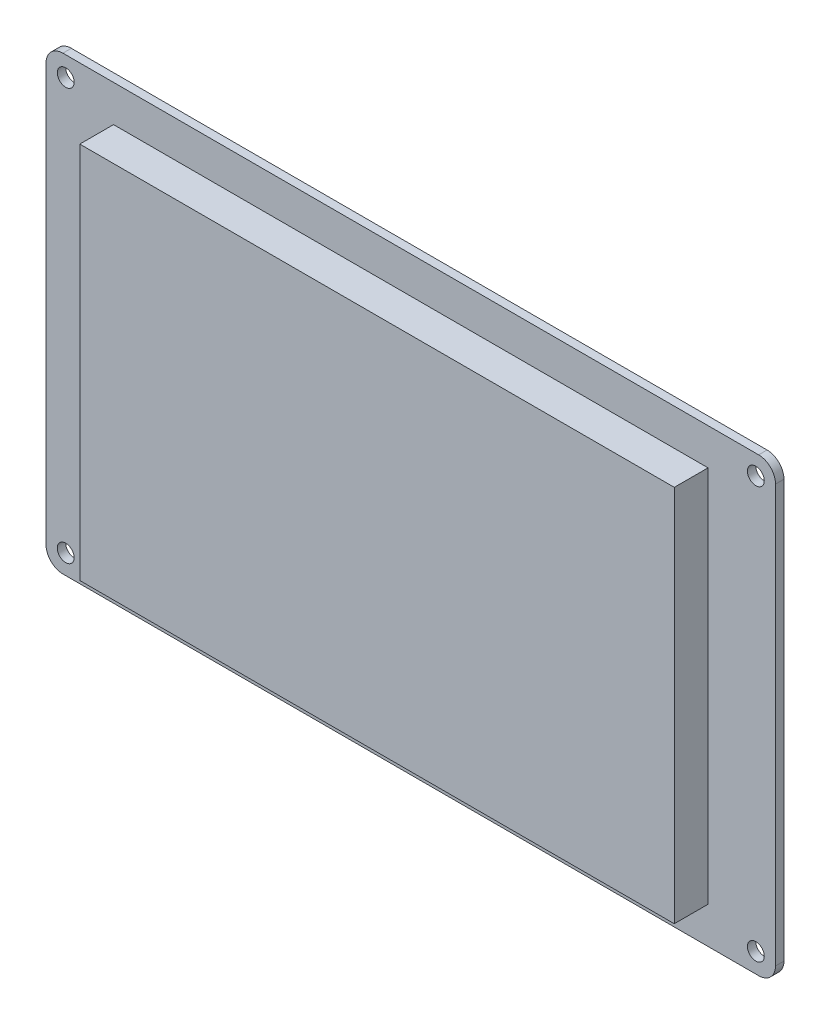
from build123d import *

# Parameters (mm, degrees)
SKETCH1_W           = 105.7
SKETCH1_H           = 67.2
BOSS_EXTRUDE1_DEPTH = 6
SKETCH2_W           = 129.7
SKETCH2_H           = 80.2
BOSS_EXTRUDE2_DEPTH = 1.5
SKETCH3_R           = 1.5
CUT_EXTRUDE1_DEPTH  = 1.5
FILLET1_R           = 3


with BuildPart() as part:
    # Sketch1 → Boss-Extrude1 (new body)
    with BuildSketch(Plane.XY):
        Rectangle(SKETCH1_W, SKETCH1_H)
    extrude(amount=BOSS_EXTRUDE1_DEPTH)

    # Sketch2 → Boss-Extrude2 (add)
    with BuildSketch(Plane(origin=(0, 0, 0), x_dir=(-1, 0, 0), z_dir=(0, 0, -1))):
        Rectangle(SKETCH2_W, SKETCH2_H)
    extrude(amount=BOSS_EXTRUDE2_DEPTH)

    # Sketch3 → Cut-Extrude1 (cut)
    with BuildSketch(Plane.XY):
        with Locations((61.35, 36.6)):
            Circle(SKETCH3_R)
        with Locations((61.35, -36.6)):
            Circle(SKETCH3_R)
        with Locations((-61.35, -36.6)):
            Circle(SKETCH3_R)
        with Locations((-61.35, 36.6)):
            Circle(SKETCH3_R)
    extrude(amount=-CUT_EXTRUDE1_DEPTH, mode=Mode.SUBTRACT)

    # Fillet1
    fillet1_edges = [part.edges().sort_by_distance(p)[0] for p in [
        (-64.85, -40.1, -0.75),
        (-64.85, 40.1, -0.75),
        (64.85, 40.1, -0.75),
        (64.85, -40.1, -0.75),
    ]]
    fillet(fillet1_edges, radius=FILLET1_R)


solid = part.part
